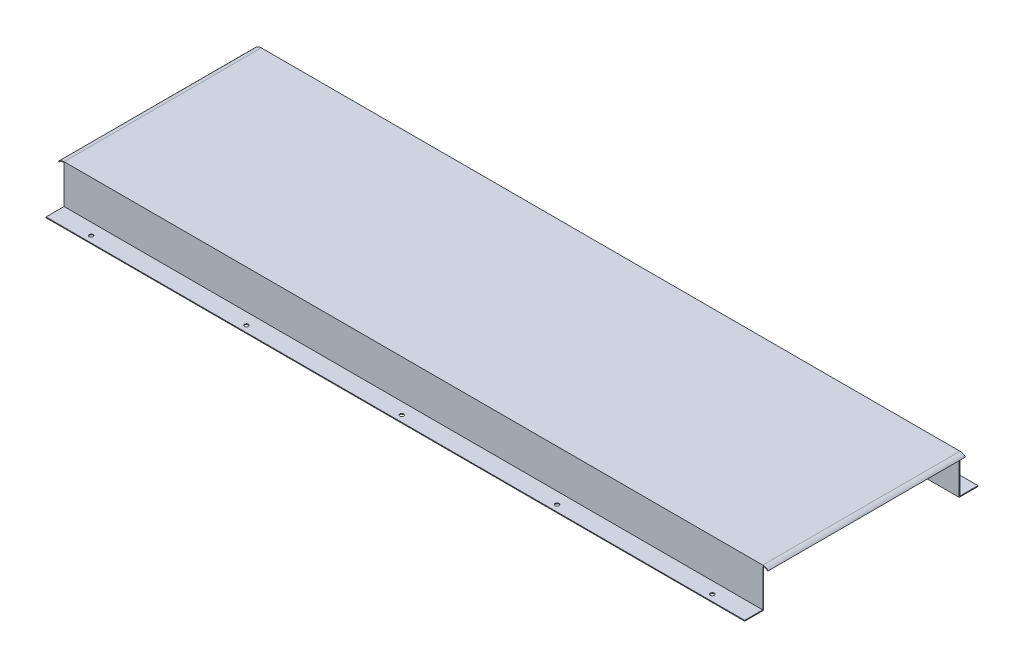
from build123d import *

# Parameters (mm, degrees)
SKETCH2_W               = 900
SKETCH2_H               = 51
BOSS_EXTRUDE1_DEPTH     = 1
SKETCH3_W               = 900
SKETCH3_H               = 1
BOSS_EXTRUDE2_DEPTH     = 23.25
BOSS_EXTRUDE3_START     = 1
SKETCH4_W               = 900
SKETCH4_H               = 1
BOSS_EXTRUDE3_DEPTH     = 126
SKETCH5_R               = 2.5
CUT_EXTRUDE1_DEPTH      = 469.272623586
LPATTERN2_COUNT         = 6
LPATTERN2_PITCH         = 200
BOSS_EXTRUDE4_DEPTH     = 127
BOSS_EXTRUDE5_DEPTH     = 127
MIRROR4_COPY_1_SKETCH_R = 2.5
MIRROR4_COPY_1_DEPTH    = 469.272623586
MIRROR4_COPY_2_SKETCH_R = 2.5
MIRROR4_COPY_2_DEPTH    = 469.272623586
MIRROR4_COPY_3_SKETCH_R = 2.5
MIRROR4_COPY_3_DEPTH    = 469.272623586
MIRROR4_COPY_4_SKETCH_R = 2.5
MIRROR4_COPY_4_DEPTH    = 469.272623586
MIRROR4_COPY_5_SKETCH_R = 2.5
MIRROR4_COPY_5_DEPTH    = 469.272623586


with BuildPart() as part:
    # Sketch2 → Boss-Extrude1 (new body)
    with BuildSketch(Plane.XY):
        Rectangle(SKETCH2_W, SKETCH2_H)
    boss_extrude1 = extrude(amount=BOSS_EXTRUDE1_DEPTH)

    # Sketch3 → Boss-Extrude2 (add)
    with BuildSketch(Plane.XY):
        with Locations((0, -25)):
            Rectangle(SKETCH3_W, SKETCH3_H)
    boss_extrude2 = extrude(amount=-BOSS_EXTRUDE2_DEPTH)

    # Sketch4 → Boss-Extrude3 (add)
    with BuildSketch(Plane.XY.offset(BOSS_EXTRUDE3_START)):
        with Locations((0, 25)):
            Rectangle(SKETCH4_W, SKETCH4_H)
    boss_extrude3 = extrude(amount=BOSS_EXTRUDE3_DEPTH)

    # Sketch5 → Cut-Extrude1 (cut, symmetric)
    with BuildSketch(Plane(origin=(0, 0, 0), x_dir=(1, 0, 0), z_dir=(0, 1, 0))):
        with Locations(Location((400, 15, 0), (0, 0, 270))):
            Circle(SKETCH5_R)
    cut_extrude1 = extrude(amount=CUT_EXTRUDE1_DEPTH, both=True, mode=Mode.SUBTRACT)

    # LPattern2: Cut-Extrude1 ×6
    with Locations(*[(-i * LPATTERN2_PITCH, 0, 0) for i in range(1, LPATTERN2_COUNT)]):
        add(cut_extrude1, mode=Mode.SUBTRACT)

    # Sketch7 → Boss-Extrude4 (add)
    with BuildSketch(Plane.XY):
        with BuildLine():
            Line((-450, 24.5), (-450, 25.5))
            ThreePointArc((-450, 25.5), (-453.826834324, 24.738795325), (-457.071067812, 22.571067812))
            Line((-457.071067812, 22.571067812), (-456.363961031, 21.863961031))
            ThreePointArc((-456.363961031, 21.863961031), (-453.444150891, 23.814915793), (-450, 24.5))
        make_face()
    boss_extrude4 = extrude(amount=BOSS_EXTRUDE4_DEPTH)

    # Sketch8 → Boss-Extrude5 (add)
    with BuildSketch(Plane.XY):
        with BuildLine():
            Line((456.363961031, 21.863961031), (457.071067812, 22.571067812))
            ThreePointArc((457.071067812, 22.571067812), (453.826834324, 24.738795325), (450, 25.5))
            Line((450, 25.5), (450, 24.5))
            ThreePointArc((450, 24.5), (453.444150891, 23.814915793), (456.363961031, 21.863961031))
        make_face()
    boss_extrude5 = extrude(amount=BOSS_EXTRUDE5_DEPTH)

    # Mirror2: Boss-Extrude3, Boss-Extrude4, Boss-Extrude5 across plane
    add(boss_extrude3.mirror(Plane.XY.offset(127)))
    add(boss_extrude4.mirror(Plane.XY.offset(127)))
    add(boss_extrude5.mirror(Plane.XY.offset(127)))

    # Mirror4: Boss-Extrude1, Boss-Extrude2, Cut-Extrude1 across plane
    add(boss_extrude1.mirror(Plane.XY.offset(127)))
    add(boss_extrude2.mirror(Plane.XY.offset(127)))
    add(cut_extrude1.mirror(Plane.XY.offset(127)), mode=Mode.SUBTRACT)

    # Mirror4 copy 1 sketch → Mirror4 copy 1 (cut, symmetric)
    with BuildSketch(Plane(origin=(-200, 0, 254), x_dir=(1, 0, 0), z_dir=(0, 1, 0))):
        with Locations((400, -15)):
            Circle(MIRROR4_COPY_1_SKETCH_R)
    extrude(amount=MIRROR4_COPY_1_DEPTH, both=True, mode=Mode.SUBTRACT)

    # Mirror4 copy 2 sketch → Mirror4 copy 2 (cut, symmetric)
    with BuildSketch(Plane(origin=(-400, 0, 254), x_dir=(1, 0, 0), z_dir=(0, 1, 0))):
        with Locations((400, -15)):
            Circle(MIRROR4_COPY_2_SKETCH_R)
    extrude(amount=MIRROR4_COPY_2_DEPTH, both=True, mode=Mode.SUBTRACT)

    # Mirror4 copy 3 sketch → Mirror4 copy 3 (cut, symmetric)
    with BuildSketch(Plane(origin=(-600, 0, 254), x_dir=(1, 0, 0), z_dir=(0, 1, 0))):
        with Locations((400, -15)):
            Circle(MIRROR4_COPY_3_SKETCH_R)
    extrude(amount=MIRROR4_COPY_3_DEPTH, both=True, mode=Mode.SUBTRACT)

    # Mirror4 copy 4 sketch → Mirror4 copy 4 (cut, symmetric)
    with BuildSketch(Plane(origin=(-800, 0, 254), x_dir=(1, 0, 0), z_dir=(0, 1, 0))):
        with Locations((400, -15)):
            Circle(MIRROR4_COPY_4_SKETCH_R)
    extrude(amount=MIRROR4_COPY_4_DEPTH, both=True, mode=Mode.SUBTRACT)

    # Mirror4 copy 5 sketch → Mirror4 copy 5 (cut, symmetric)
    with BuildSketch(Plane(origin=(-1000, 0, 254), x_dir=(1, 0, 0), z_dir=(0, 1, 0))):
        with Locations((400, -15)):
            Circle(MIRROR4_COPY_5_SKETCH_R)
    extrude(amount=MIRROR4_COPY_5_DEPTH, both=True, mode=Mode.SUBTRACT)


solid = part.part
